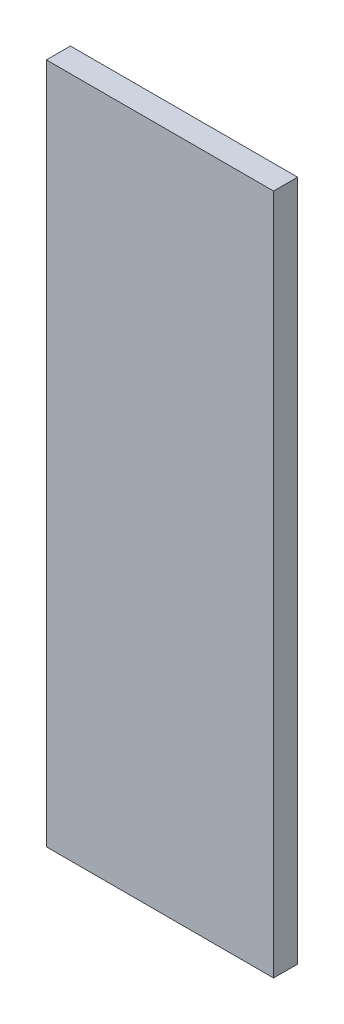
from build123d import *

# Parameters (mm, degrees)
SKETCH1_W           = 30
SKETCH1_H           = 90
BOSS_EXTRUDE1_DEPTH = 3.175


with BuildPart() as part:
    # Sketch1 → Boss-Extrude1 (new body)
    with BuildSketch(Plane.XY):
        Rectangle(SKETCH1_W, SKETCH1_H)
    extrude(amount=BOSS_EXTRUDE1_DEPTH)


solid = part.part
